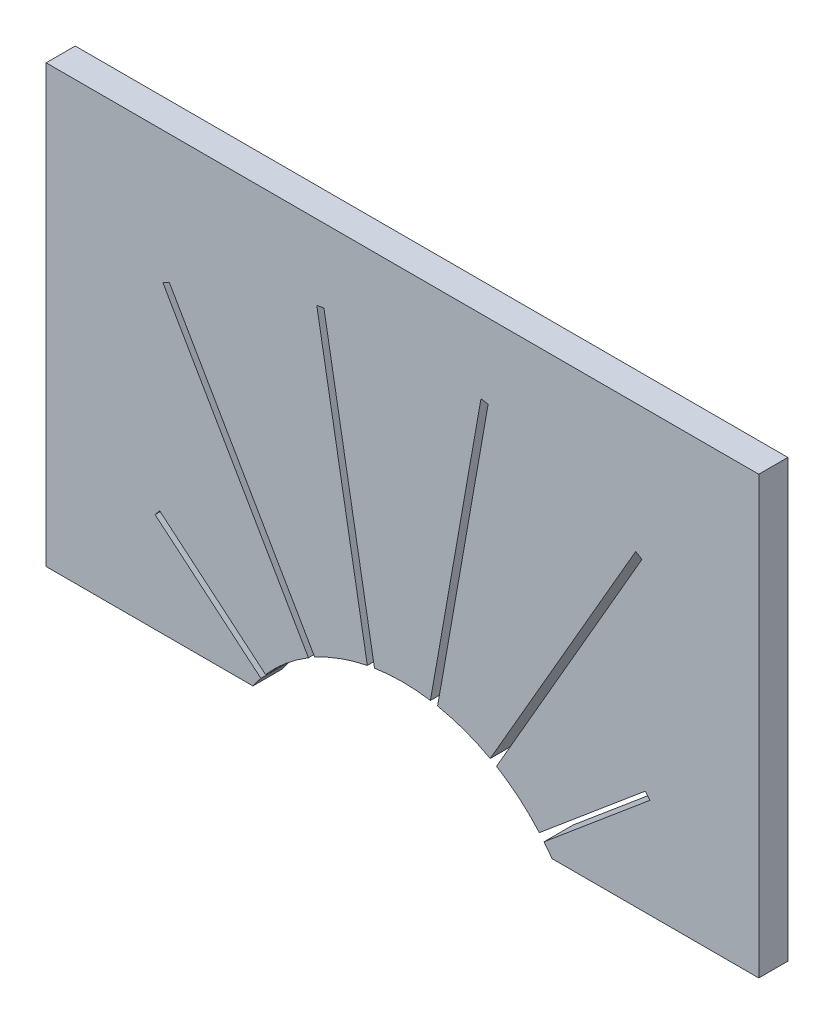
from build123d import *

# Parameters (mm, degrees)
SKETCH1_W           = 49
SKETCH1_H           = 30
BOSS_EXTRUDE1_DEPTH = 1
CUT_EXTRUDE1_DEPTH  = 10


with BuildPart() as part:
    # Sketch1 → Boss-Extrude1 (new body, symmetric)
    with BuildSketch(Plane.XY):
        Rectangle(SKETCH1_W, SKETCH1_H)
    extrude(amount=BOSS_EXTRUDE1_DEPTH, both=True)

    # Sketch2 → Cut-Extrude1 (cut)
    with BuildSketch(Plane.XY.offset(1)):
        with BuildLine():
            Line((-9.734337139, -14.270273119), (-17.013674651, -8.162183698))
            Line((-17.013674651, -8.162183698), (-16.692280846, -7.779161476))
            Line((-16.692280846, -7.779161476), (-9.412943334, -13.887250898))
            ThreePointArc((-9.412943334, -13.887250898), (-8.034845121, -12.536444461), (-6.465256226, -11.413847733))
            Line((-6.465256226, -11.413847733), (-16.471025722, 5.916653404))
            ThreePointArc((-16.471025722, 5.916653404), (-16.255, 6.042485877), (-16.038013021, 6.166653404))
            Line((-16.038013021, 6.166653404), (-6.032243524, -11.163847733))
            ThreePointArc((-6.032243524, -11.163847733), (-4.275251792, -10.36584224), (-2.416369995, -9.847777397))
            Line((-2.416369995, -9.847777397), (-5.891337274, 9.859741353))
            ThreePointArc((-5.891337274, 9.859741353), (-5.645302256, 9.90410005), (-5.398933397, 9.946565442))
            Line((-5.398933397, 9.946565442), (-1.923966119, -9.760953309))
            ThreePointArc((-1.923966119, -9.760953309), (0, -9.612), (1.923966119, -9.760953309))
            Line((1.923966119, -9.760953309), (5.398933397, 9.946565442))
            ThreePointArc((5.398933397, 9.946565442), (5.645302256, 9.90410005), (5.891337274, 9.859741353))
            Line((5.891337274, 9.859741353), (2.416369995, -9.847777397))
            ThreePointArc((2.416369995, -9.847777397), (4.275251792, -10.36584224), (6.032243524, -11.163847733))
            Line((6.032243524, -11.163847733), (16.038013021, 6.166653404))
            ThreePointArc((16.038013021, 6.166653404), (16.255, 6.042485877), (16.471025722, 5.916653404))
            Line((16.471025722, 5.916653404), (6.465256226, -11.413847733))
            ThreePointArc((6.465256226, -11.413847733), (8.034845121, -12.536444461), (9.412943334, -13.887250898))
            Line((9.412943334, -13.887250898), (16.692280846, -7.779161476))
            Line((16.692280846, -7.779161476), (17.013674651, -8.162183698))
            Line((17.013674651, -8.162183698), (9.734337139, -14.270273119))
            ThreePointArc((9.734337139, -14.270273119), (10.013600489, -14.630168322), (10.279564971, -15))
            Line((10.279564971, -15), (-10.279564971, -15))
            ThreePointArc((-10.279564971, -15), (-10.013600489, -14.630168322), (-9.734337139, -14.270273119))
        make_face()
    extrude(amount=-CUT_EXTRUDE1_DEPTH, mode=Mode.SUBTRACT)


solid = part.part
